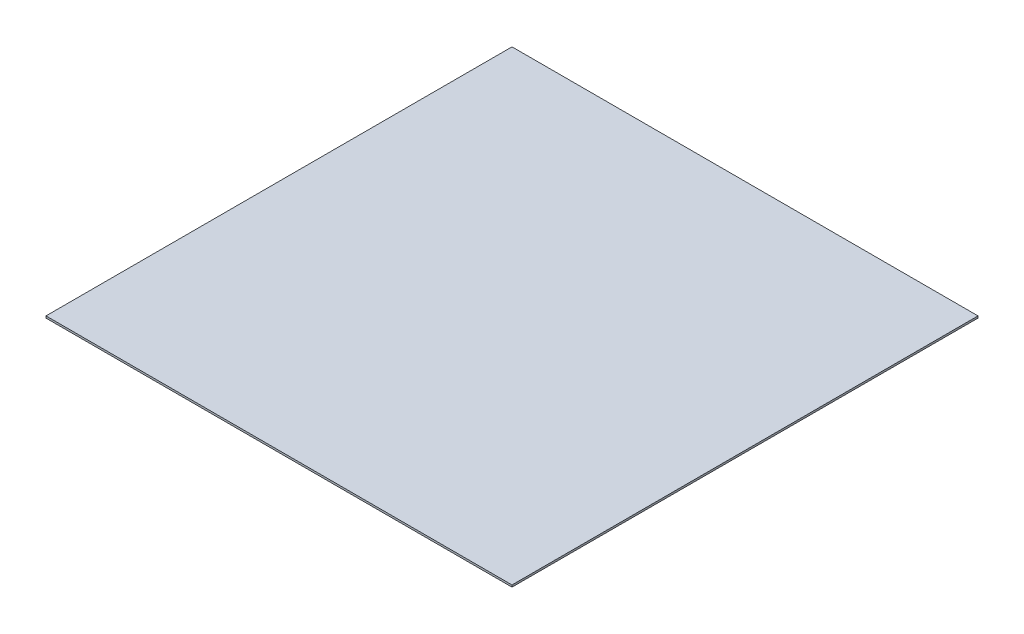
from build123d import *

# Parameters (mm, degrees)
SKETCH1_W           = 12000
SKETCH1_H           = 12000
BOSS_EXTRUDE1_DEPTH = 50


with BuildPart() as part:
    # Sketch1 → Boss-Extrude1 (new body)
    with BuildSketch(Plane(origin=(0, 0, 0), x_dir=(1, 0, 0), z_dir=(0, 1, 0))):
        Rectangle(SKETCH1_W, SKETCH1_H)
    extrude(amount=BOSS_EXTRUDE1_DEPTH)


solid = part.part
